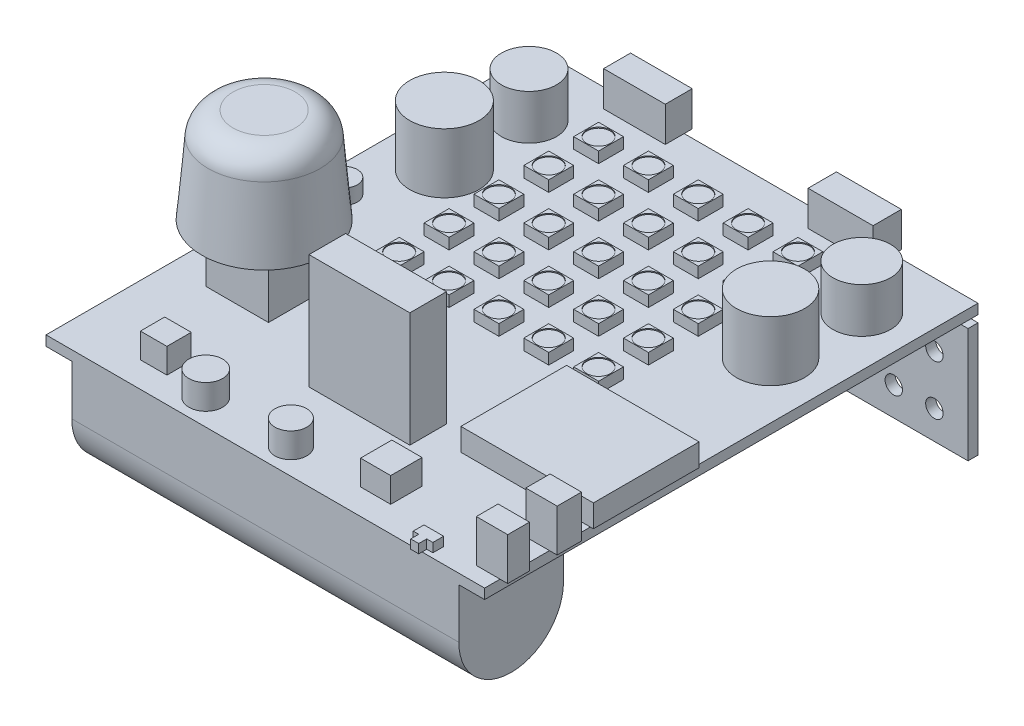
from build123d import *

# Parameters (mm, degrees)
ESBO_O1_W                 = 88
ESBO_O1_H                 = 99
RESSALTO_EXTRUS_O1_DEPTH  = 2
ESBO_O2_W                 = 2
ESBO_O2_H                 = 23
RESSALTO_EXTRUS_O2_DEPTH  = 44
RESSALTO_EXTRUS_O3_DEPTH  = 38.83
ESBO_O4_W                 = 2.36
ESBO_O4_H                 = 8.3
RESSALTO_EXTRUS_O4_DEPTH  = 9.4
CORTE_EXTRUS_O1_DEPTH     = 2
RESSALTO_EXTRUS_O5_START  = 12
ESBO_O6_R                 = 12.5
RESSALTO_EXTRUS_O5_DEPTH  = 19
RESSALTO_EXTRUS_O5_TAPER  = 5
ESBO_O6_3_W               = 20.229841012
ESBO_O6_3_H               = 7.337821928
RESSALTO_EXTRUS_O6_DEPTH  = 23
ESBO_O6_4_R               = 6.961523519
ESBO_O6_4_R_2             = 6.852330327
RESSALTO_EXTRUS_O7_DEPTH  = 12
ESBO_O6_5_R               = 5.532469669
ESBO_O6_5_R_2             = 5.799556289
RESSALTO_EXTRUS_O8_DEPTH  = 9
ESBO_O6_6_R               = 2.649840985
RESSALTO_EXTRUS_O9_DEPTH  = 3
ESBO_O6_7_W               = 13.030807046
ESBO_O6_7_H               = 5.675096047
ESBO_O6_7_W_2             = 12.376058313
ESBO_O6_7_H_2             = 5.408850482
RESSALTO_EXTRUS_O10_DEPTH = 7
ESBO_O6_8_W               = 26.589159873
ESBO_O6_8_H               = 21.20934228
RESSALTO_EXTRUS_O11_DEPTH = 4.5
FILETE1_R                 = 5
ESBO_O6_9_W               = 6.297539681
ESBO_O6_9_H               = 4.885977668
ESBO_O6_9_H_2             = 4.372191485
RESSALTO_EXTRUS_O12_DEPTH = 8.5
ESBO_O6_10_R              = 3.386329978
ESBO_O6_10_R_2            = 3.2013981
ESBO_O6_10_W              = 5.317465875
ESBO_O6_10_H              = 4.878645502
ESBO_O6_10_W_2            = 6.056647195
ESBO_O6_10_H_2            = 6.287891713
RESSALTO_EXTRUS_O13_DEPTH = 5
ESBO_O6_11_W              = 4.669035977
ESBO_O6_11_H              = 4.058995238
RESSALTO_EXTRUS_O14_DEPTH = 1.8
ESBO_O7_W                 = 5
ESBO_O7_H                 = 5
RESSALTO_EXTRUS_O15_DEPTH = 2.2
ESBO_O8_R                 = 2.35
CORTE_EXTRUS_O2_DEPTH     = 0.2
PADR_O_LINEAR1_COUNT      = 5
PADR_O_LINEAR1_PITCH      = 10
PADR_O_LINEAR1_COUNT_DIR2 = 5
PADR_O_LINEAR1_PITCH_DIR2 = 10
ESBO_O6_12_W              = 12.508733232
ESBO_O6_12_H              = 11.090335048
RESSALTO_EXTRUS_O16_DEPTH = 20
ESBO_O9_R                 = 1.75
CORTE_EXTRUS_O3_DEPTH     = 2
PADR_O_LINEAR2_COUNT      = 5
PADR_O_LINEAR2_PITCH      = 7.25
PADR_O_LINEAR2_COUNT_DIR2 = 2
PADR_O_LINEAR2_PITCH_DIR2 = 10
ESBO_O10_R                = 1.75
CORTE_EXTRUS_O4_DEPTH     = 2
PADR_O_LINEAR3_COUNT      = 4
PADR_O_LINEAR3_PITCH      = 8.15
PADR_O_LINEAR3_COUNT_DIR2 = 2
PADR_O_LINEAR3_PITCH_DIR2 = 10


with BuildPart() as part:
    # Esboço1 → Ressalto-extrusão1 (new body)
    with BuildSketch(Plane(origin=(0, 0, 0), x_dir=(1, 0, 0), z_dir=(0, 1, 0))):
        Rectangle(ESBO_O1_W, ESBO_O1_H)
    extrude(amount=RESSALTO_EXTRUS_O1_DEPTH)

    # Esboço3 → Ressalto-extrusão3 (add, symmetric)
    with BuildSketch(Plane(origin=(0, 0, 0), x_dir=(0, 0, -1), z_dir=(1, 0, 0))):
        with BuildLine():
            Line((-28.5, 0), (-49.5, 0))
            Line((-49.5, 0), (-49.5, -10))
            ThreePointArc((-49.5, -10), (-39, -20.5), (-28.5, -10))
            Line((-28.5, -10), (-28.5, 0))
        make_face()
    extrude(amount=RESSALTO_EXTRUS_O3_DEPTH, both=True)

    # Esboço4 → Ressalto-extrusão4 (add)
    with BuildSketch(Plane.XZ):
        with Locations((-24.46, -21.55)):
            Rectangle(ESBO_O4_W, ESBO_O4_H)
    extrude(amount=RESSALTO_EXTRUS_O4_DEPTH)

    # Esboço6<3> → Ressalto-extrusão6 (add)
    with BuildSketch(Plane(origin=(0, 2, 0), x_dir=(1, 0, 0), z_dir=(0, 1, 0))):
        with Locations((1.555980781, -28.501734688)):
            Rectangle(ESBO_O6_3_W, ESBO_O6_3_H)
    extrude(amount=RESSALTO_EXTRUS_O6_DEPTH)

    # Esboço6<4> → Ressalto-extrusão7 (add)
    with BuildSketch(Plane(origin=(0, 2, 0), x_dir=(1, 0, 0), z_dir=(0, 1, 0))):
        with Locations((-32.757158137, 19.192558272)):
            Circle(ESBO_O6_4_R)
        with Locations((32.682733845, 19.192558272)):
            Circle(ESBO_O6_4_R_2)
    extrude(amount=RESSALTO_EXTRUS_O7_DEPTH)

    # Esboço6<5> → Ressalto-extrusão8 (add)
    with BuildSketch(Plane(origin=(0, 2, 0), x_dir=(1, 0, 0), z_dir=(0, 1, 0))):
        with Locations((-32.757158137, 36.166568935)):
            Circle(ESBO_O6_5_R)
        with Locations((34.006886809, 36.166568935)):
            Circle(ESBO_O6_5_R_2)
    extrude(amount=RESSALTO_EXTRUS_O8_DEPTH)

    # Esboço6<6> → Ressalto-extrusão9 (add)
    with BuildSketch(Plane(origin=(0, 2, 0), x_dir=(1, 0, 0), z_dir=(0, 1, 0))):
        with Locations((-38.488963685, 4.811718736)):
            Circle(ESBO_O6_6_R)
    extrude(amount=RESSALTO_EXTRUS_O9_DEPTH)

    # Esboço6<7> → Ressalto-extrusão10 (add)
    with BuildSketch(Plane(origin=(0, 2, 0), x_dir=(1, 0, 0), z_dir=(0, 1, 0))):
        with Locations((20.487295683, 48.275969897)):
            Rectangle(ESBO_O6_7_W, ESBO_O6_7_H)
        with Locations((-21.139616205, 48.409092679)):
            Rectangle(ESBO_O6_7_W_2, ESBO_O6_7_H_2)
    extrude(amount=RESSALTO_EXTRUS_O10_DEPTH)

    # Esboço6<8> → Ressalto-extrusão11 (add)
    with BuildSketch(Plane(origin=(0, 2, 0), x_dir=(1, 0, 0), z_dir=(0, 1, 0))):
        with Locations((31.320313171, -17.675050847)):
            Rectangle(ESBO_O6_8_W, ESBO_O6_8_H)
    extrude(amount=RESSALTO_EXTRUS_O11_DEPTH)

    # Esboço6<9> → Ressalto-extrusão12 (add)
    with BuildSketch(Plane(origin=(0, 2, 0), x_dir=(1, 0, 0), z_dir=(0, 1, 0))):
        with Locations((42.387345581, -34.035128775)):
            Rectangle(ESBO_O6_9_W, ESBO_O6_9_H)
        with Locations((42.387345581, -44.211051814)):
            Rectangle(ESBO_O6_9_W, ESBO_O6_9_H_2)
    extrude(amount=RESSALTO_EXTRUS_O12_DEPTH)

    # Esboço6<10> → Ressalto-extrusão13 (add)
    with BuildSketch(Plane(origin=(0, 2, 0), x_dir=(1, 0, 0), z_dir=(0, 1, 0))):
        with Locations((-17.081492117, -44.366010172)):
            Circle(ESBO_O6_10_R)
        with Locations((0, -44.366010172)):
            Circle(ESBO_O6_10_R_2)
        with Locations((-27.532762745, -41.926687421)):
            Rectangle(ESBO_O6_10_W, ESBO_O6_10_H)
        with Locations((17.000215758, -41.222064316)):
            Rectangle(ESBO_O6_10_W_2, ESBO_O6_10_H_2)
    extrude(amount=RESSALTO_EXTRUS_O13_DEPTH)

    # Esboço6<11> → Ressalto-extrusão14 (add)
    with BuildSketch(Plane(origin=(0, 2, 0), x_dir=(1, 0, 0), z_dir=(0, 1, 0))):
        Polygon((32.682733845, -46.397147556), (28.743852839, -46.397147556), (28.743852839, -48.561061134), (29.839189529, -48.561061134), (29.839189529, -50.16069933), (31.450117116, -50.16069933), (31.450117116, -48.561061134), (32.682733845, -48.561061134), align=None)
        with Locations((1.602664827, -21.564867082)):
            Rectangle(ESBO_O6_11_W, ESBO_O6_11_H)
    extrude(amount=RESSALTO_EXTRUS_O14_DEPTH)

    # Esboço7 → Ressalto-extrusão15 (add)
    with BuildSketch(Plane(origin=(0, 2, 0), x_dir=(1, 0, 0), z_dir=(0, 1, 0))):
        with Locations((19.190930272, 38.178364347)):
            Rectangle(ESBO_O7_W, ESBO_O7_H)
    ressalto_extrus_o15 = extrude(amount=RESSALTO_EXTRUS_O15_DEPTH)

    # Esboço8 → Corte-extrusão2 (cut)
    with BuildSketch(Plane(origin=(0, 4.2, 0), x_dir=(1, 0, 0), z_dir=(0, 1, 0))):
        with Locations((19.190930272, 38.178364347)):
            Circle(ESBO_O8_R)
    corte_extrus_o2 = extrude(amount=-CORTE_EXTRUS_O2_DEPTH, mode=Mode.SUBTRACT)

    # Padrão linear1: Ressalto-extrusão15, Corte-extrus_o2 5 × 5
    with Locations(*[(-j * PADR_O_LINEAR1_PITCH_DIR2, 0, i * PADR_O_LINEAR1_PITCH) for i in range(PADR_O_LINEAR1_COUNT) for j in range(PADR_O_LINEAR1_COUNT_DIR2) if (i, j) != (0, 0)]):
        add(ressalto_extrus_o15)
        add(corte_extrus_o2, mode=Mode.SUBTRACT)



with BuildPart() as body_2:
    # Esboço2 → Ressalto-extrusão2 (new body, symmetric)
    with BuildSketch(Plane(origin=(0, 0, 0), x_dir=(0, 0, -1), z_dir=(1, 0, 0))):
        with Locations((48.5, -12.9)):
            Rectangle(ESBO_O2_W, ESBO_O2_H)
    extrude(amount=RESSALTO_EXTRUS_O2_DEPTH, both=True)

    # Esboço5 → Corte-extrusão1 (cut)
    with BuildSketch(Plane(origin=(0, 0, -49.5), x_dir=(-1, 0, 0), z_dir=(0, 0, -1))):
        with BuildLine():
            Line((5.056264055, -1.4), (5.056264055, -16.043559307))
            ThreePointArc((5.056264055, -16.043559307), (4.134681717, -18.231214297), (1.925528085, -19.1))
            Line((1.925528085, -19.1), (-5.747295252, -19.1))
            ThreePointArc((-5.747295252, -19.1), (-7.908525192, -18.204789247), (-8.803735945, -16.043559307))
            Line((-8.803735945, -16.043559307), (-8.803735945, -1.4))
            Line((-8.803735945, -1.4), (5.056264055, -1.4))
        make_face()
    extrude(amount=-CORTE_EXTRUS_O1_DEPTH, mode=Mode.SUBTRACT)

    # Esboço9 → Corte-extrusão3 (cut)
    with BuildSketch(Plane(origin=(0, 0, -49.5), x_dir=(-1, 0, 0), z_dir=(0, 0, -1))):
        with Locations((40.33, -18.65)):
            Circle(ESBO_O9_R)
    corte_extrus_o3 = extrude(amount=-CORTE_EXTRUS_O3_DEPTH, mode=Mode.SUBTRACT)

    # Padrão linear2: Corte-extrus_o3 5 × 2
    with Locations(*[(i * PADR_O_LINEAR2_PITCH, j * PADR_O_LINEAR2_PITCH_DIR2, 0) for i in range(PADR_O_LINEAR2_COUNT) for j in range(PADR_O_LINEAR2_COUNT_DIR2) if (i, j) != (0, 0)]):
        add(corte_extrus_o3, mode=Mode.SUBTRACT)

    # Esboço10 → Corte-extrusão4 (cut)
    with BuildSketch(Plane(origin=(0, 0, -49.5), x_dir=(-1, 0, 0), z_dir=(0, 0, -1))):
        with Locations((-37.25, -18.65)):
            Circle(ESBO_O10_R)
    corte_extrus_o4 = extrude(amount=-CORTE_EXTRUS_O4_DEPTH, mode=Mode.SUBTRACT)

    # Padrão linear3: Corte-extrus_o4 4 × 2
    with Locations(*[(-i * PADR_O_LINEAR3_PITCH, j * PADR_O_LINEAR3_PITCH_DIR2, 0) for i in range(PADR_O_LINEAR3_COUNT) for j in range(PADR_O_LINEAR3_COUNT_DIR2) if (i, j) != (0, 0)]):
        add(corte_extrus_o4, mode=Mode.SUBTRACT)


with BuildPart() as body_3:
    # Esboço6 → Ressalto-extrusão5 (new body)
    with BuildSketch(Plane(origin=(0, 2, 0), x_dir=(1, 0, 0), z_dir=(0, 1, 0)).offset(RESSALTO_EXTRUS_O5_START)):
        with Locations((-30.191495682, -19.535369463)):
            Circle(ESBO_O6_R)
    extrude(amount=RESSALTO_EXTRUS_O5_DEPTH, taper=RESSALTO_EXTRUS_O5_TAPER)

    # Filete1
    filete1_edges = [body_3.edges().sort_by_distance(p)[0] for p in [
        (-41.029211075, 33, 19.535369463),
    ]]
    fillet(filete1_edges, radius=FILETE1_R)


with BuildPart() as part_1:
    add(part.part)

    add(body_3.part)  # Ressalto-extrusão16 merges body 3
    # Esboço6<12> → Ressalto-extrusão16 (add)
    with BuildSketch(Plane(origin=(0, 2, 0), x_dir=(1, 0, 0), z_dir=(0, 1, 0))):
        with Locations((-30.075282682, -19.490335035)):
            Rectangle(ESBO_O6_12_W, ESBO_O6_12_H)
    extrude(amount=RESSALTO_EXTRUS_O16_DEPTH)


solid = Compound([body_2.part, part_1.part])
